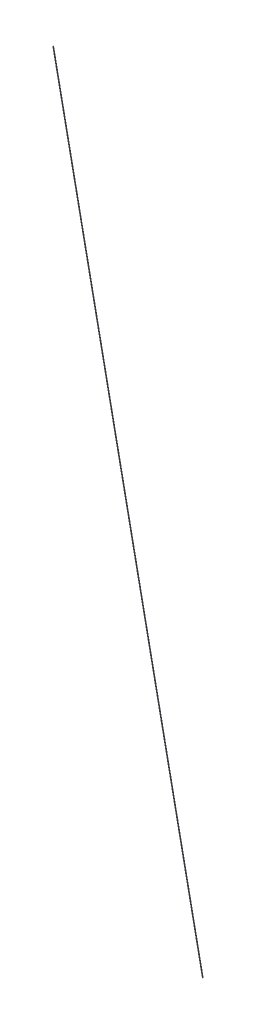
from build123d import *

# Parameters (mm, degrees)
SWEEP_2_PROFILE_R = 0.5


with BuildPart() as part:
    # 扫描2: sweep along a path in 草图2
    with BuildLine(Plane.XY) as sweep_2_path:
        Line((307.5, 0), (0, 1505))
    # 扫描2 profile (on start of the path) → 扫描2 (sweep)
    with BuildSketch(Plane(origin=(307.5, 0, 0), x_dir=(0.979758481, 0.200183211, 0), z_dir=(-0.200183211, 0.979758481, 0))):
        Circle(SWEEP_2_PROFILE_R)
    sweep(path=sweep_2_path.line)


solid = part.part
